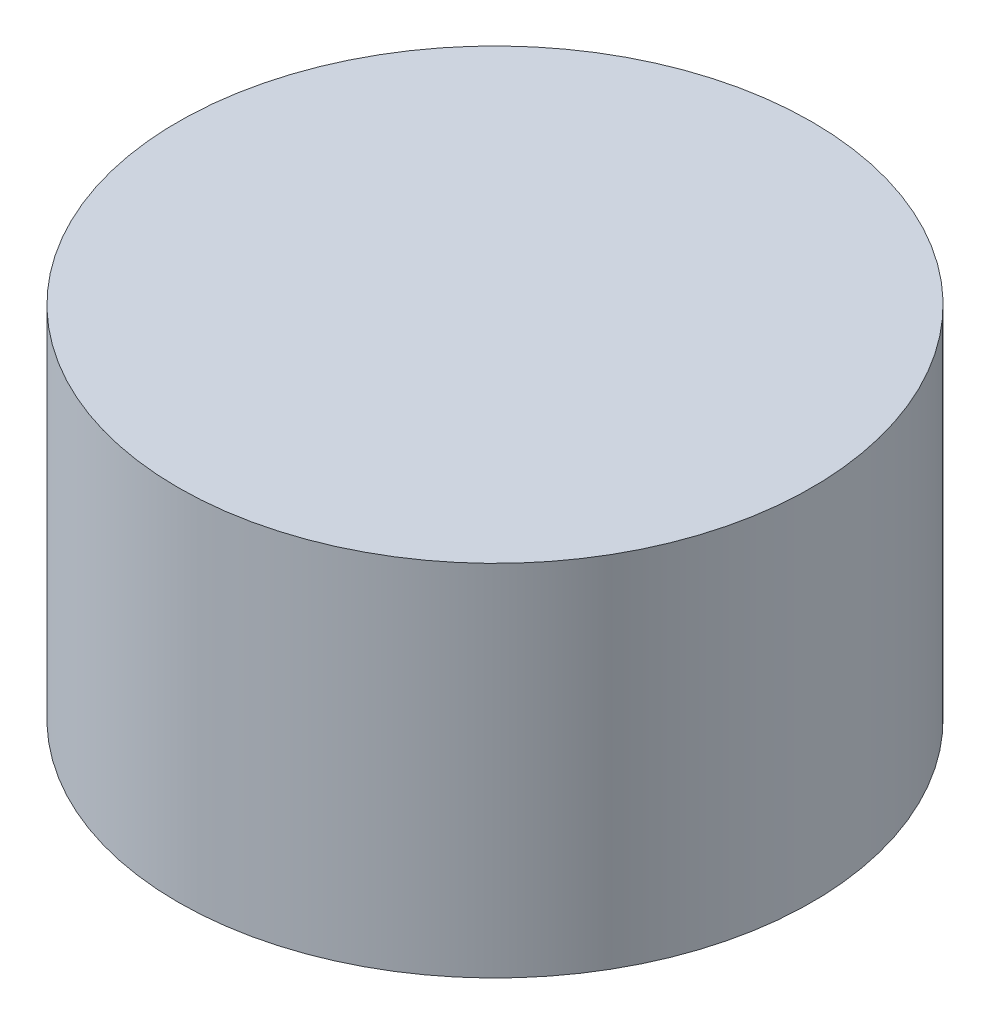
from build123d import *

# Parameters (mm, degrees)
SKETCH2_R           = 15
BOSS_EXTRUDE1_DEPTH = 17


with BuildPart() as part:
    # Sketch2 → Boss-Extrude1 (new body)
    with BuildSketch(Plane(origin=(0, 0, 0), x_dir=(1, 0, 0), z_dir=(0, 1, 0))):
        Circle(SKETCH2_R)
    extrude(amount=BOSS_EXTRUDE1_DEPTH)


solid = part.part
